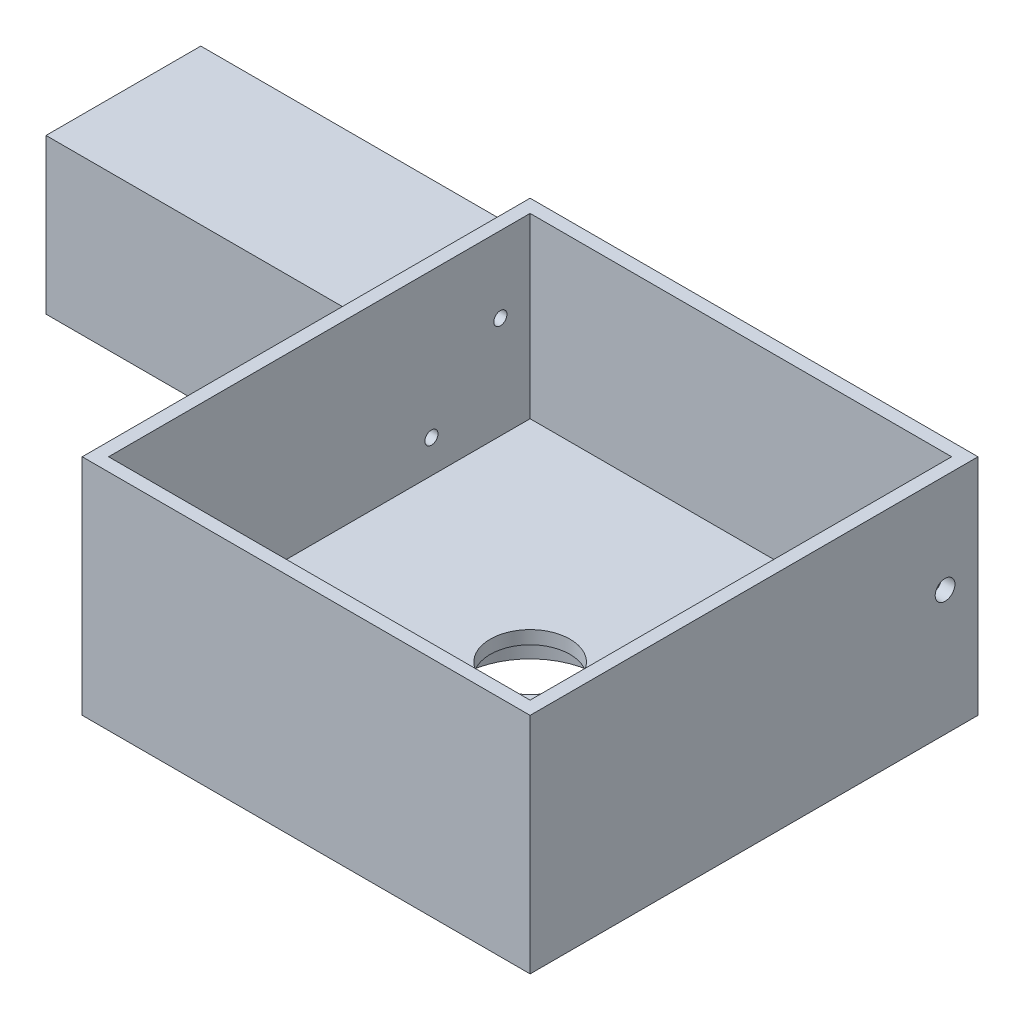
from build123d import *

# Parameters (mm, degrees)
SKETCH1_W           = 68
SKETCH1_H           = 68
BOSS_EXTRUDE1_DEPTH = 34
CUT_EXTRUDE1_START  = 34
SKETCH2_W           = 64
SKETCH2_H           = 64
CUT_EXTRUDE1_DEPTH  = 27
SKETCH6_R           = 10.5
CUT_EXTRUDE10_DEPTH = 5
SKETCH7_W           = 30
SKETCH7_H           = 30
SKETCH7_W_2         = 26
SKETCH7_H_2         = 26
CUT_EXTRUDE11_DEPTH = 2
SKETCH8_R           = 1.5
CUT_EXTRUDE12_DEPTH = 3
SKETCH9_W           = 23.5
SKETCH9_H           = 23.5
SKETCH9_R           = 5.6
BOSS_EXTRUDE4_DEPTH = 50
SKETCH11_R          = 1
CUT_EXTRUDE13_DEPTH = 52
SKETCH5_R           = 6.05
CUT_EXTRUDE14_DEPTH = 35
FILLET1_R           = 0.5


with BuildPart() as part:
    # Sketch1 → Boss-Extrude1 (new body)
    with BuildSketch(Plane(origin=(0, 0, 0), x_dir=(1, 0, 0), z_dir=(0, 1, 0))):
        Rectangle(SKETCH1_W, SKETCH1_H)
    extrude(amount=BOSS_EXTRUDE1_DEPTH)

    # Sketch2 → Cut-Extrude1 (cut)
    with BuildSketch(Plane(origin=(0, 0, 0), x_dir=(1, 0, 0), z_dir=(0, 1, 0)).offset(CUT_EXTRUDE1_START)):
        Rectangle(SKETCH2_W, SKETCH2_H)
    extrude(amount=-CUT_EXTRUDE1_DEPTH, mode=Mode.SUBTRACT)

    # Sketch6 → Cut-Extrude10 (cut)
    with BuildSketch(Plane.XZ):
        Circle(SKETCH6_R)
    extrude(amount=-CUT_EXTRUDE10_DEPTH, mode=Mode.SUBTRACT)

    # Sketch7 → Cut-Extrude11 (cut)
    with BuildSketch(Plane(origin=(0, 0, 0), x_dir=(-1, 0, 0), z_dir=(0, -1, 0))):
        Rectangle(SKETCH7_W, SKETCH7_H)
        Rectangle(SKETCH7_W_2, SKETCH7_H_2, mode=Mode.SUBTRACT)
    extrude(amount=-CUT_EXTRUDE11_DEPTH, mode=Mode.SUBTRACT)

    # Sketch8 → Cut-Extrude12 (cut, through all)
    with BuildSketch(Plane.ZY.offset(-32)):
        with Locations((-29, 19)):
            Circle(SKETCH8_R)
    extrude(amount=-CUT_EXTRUDE12_DEPTH, mode=Mode.SUBTRACT)

    # Sketch9 → Boss-Extrude4 (add)
    with BuildSketch(Plane.ZY.offset(34)):
        with Locations((-22.25, 17.25)):
            Rectangle(SKETCH9_W, SKETCH9_H)
        with Locations((-22.25, 17.25)):
            Circle(SKETCH9_R, mode=Mode.SUBTRACT)
    extrude(amount=BOSS_EXTRUDE4_DEPTH)

    # Sketch11 → Cut-Extrude13 (cut)
    with BuildSketch(Plane.ZY.offset(84)):
        with Locations((-27.482590181, 22.482590181)):
            Circle(SKETCH11_R)
        with Locations((-17.017409819, 12.017409819)):
            Circle(SKETCH11_R)
    extrude(amount=-CUT_EXTRUDE13_DEPTH, mode=Mode.SUBTRACT)

    # Sketch5 → Cut-Extrude14 (cut, through all)
    with BuildSketch(Plane(origin=(0, 0, 0), x_dir=(1, 0, 0), z_dir=(0, 1, 0))):
        Circle(SKETCH5_R)
    extrude(amount=CUT_EXTRUDE14_DEPTH, mode=Mode.SUBTRACT)

    # Fillet1
    fillet1_edges = [part.edges().sort_by_distance(p)[0] for p in [
        (15, 0, 0),
        (0, 0, 15),
        (-15, 0, 0),
        (0, 0, -15),
        (13, 0, 0),
        (0, 0, -13),
        (-13, 0, 0),
        (0, 0, 13),
    ]]
    fillet(fillet1_edges, radius=FILLET1_R)


solid = part.part
